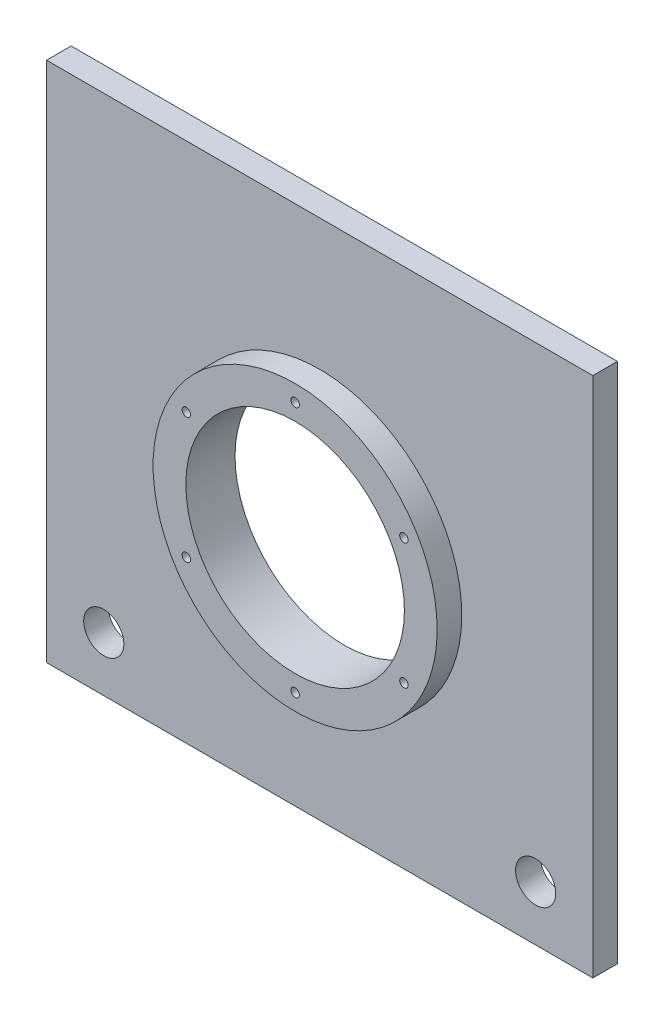
from build123d import *

# Parameters (mm, degrees)
SKETCH_1_W          = 200
SKETCH_1_H          = 191
SKETCH_1_R          = 40
SKETCH_1_R_2        = 7.35
EXTRUDE_1_DEPTH     = 9
SKETCH_2_R          = 52
SKETCH_2_R_2        = 40
EXTRUDE_2_DEPTH     = 9
SKETCH_3_R          = 1.55
CUT_EXTRUDE_1_DEPTH = 9


with BuildPart() as part:
    # 草图1 → 凸台-拉伸1 (new body)
    with BuildSketch(Plane.XY):
        Rectangle(SKETCH_1_W, SKETCH_1_H)
        with Locations((0, -4.5)):
            Circle(SKETCH_1_R, mode=Mode.SUBTRACT)
        with Locations((-79.057591623, -75.5)):
            Circle(SKETCH_1_R_2, mode=Mode.SUBTRACT)
        with Locations((79.057591623, -75.5)):
            Circle(SKETCH_1_R_2, mode=Mode.SUBTRACT)
    extrude(amount=EXTRUDE_1_DEPTH)

    # 草图2 → 凸台-拉伸2 (add)
    with BuildSketch(Plane.XY.offset(9)):
        with Locations((0, -4.5)):
            Circle(SKETCH_2_R)
        with Locations((0, -4.5)):
            Circle(SKETCH_2_R_2, mode=Mode.SUBTRACT)
    extrude(amount=EXTRUDE_2_DEPTH)

    # 草图3 → 切除-拉伸1 (cut)
    with BuildSketch(Plane.XY.offset(18)):
        with Locations((1e-09, 41.5)):
            Circle(SKETCH_3_R)
        with Locations((39.837168574, 18.5)):
            Circle(SKETCH_3_R)
        with Locations((39.837168574, -27.5)):
            Circle(SKETCH_3_R)
        with Locations((0, -50.5)):
            Circle(SKETCH_3_R)
        with Locations((-39.837168574, -27.5)):
            Circle(SKETCH_3_R)
        with Locations((-39.837168574, 18.5)):
            Circle(SKETCH_3_R)
    extrude(amount=-CUT_EXTRUDE_1_DEPTH, mode=Mode.SUBTRACT)


solid = part.part
